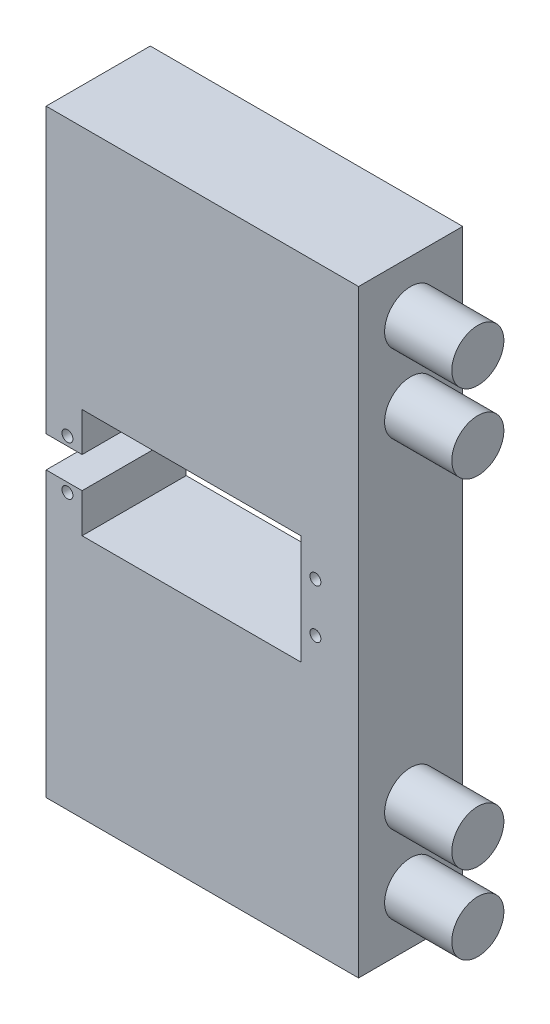
from build123d import *

# Parameters (mm, degrees)
SKETCH_5_W           = 60
SKETCH_5_H           = 115
EXTRUDE_2_DEPTH      = 20
SKETCH_1_R           = 1.05
CUT_EXTRUDE_4_DEPTH  = 20
SKETCH_6_R           = 5
EXTRUDE_3_DEPTH      = 13
SKETCH_22_W          = 21
SKETCH_22_H          = 21
CUT_EXTRUDE_9_DEPTH  = 17
SKETCH_22_6_W        = 21
SKETCH_22_6_H        = 21
CUT_EXTRUDE_10_DEPTH = 17


with BuildPart() as part:
    # Sketch 5 → Extrude 2 (new body)
    with BuildSketch(Plane.XY):
        with Locations((85.095319229, -3)):
            Rectangle(SKETCH_5_W, SKETCH_5_H)
    extrude(amount=EXTRUDE_2_DEPTH)

    # Sketch 1 → Cut-Extrude 4 (cut)
    with BuildSketch(Plane.XY):
        with Locations((59.19, 1.7)):
            Circle(SKETCH_1_R)
        with Locations((106.81, 1.7)):
            Circle(SKETCH_1_R)
        with Locations((106.81, -7.7)):
            Circle(SKETCH_1_R)
        with Locations((59.19, -7.7)):
            Circle(SKETCH_1_R)
        Polygon((55, -3), (55, 0), (62, 0), (62, 7.5), (104, 7.5), (104, -13.5), (62, -13.5), (62, -6), (55, -6), align=None)
    extrude(amount=CUT_EXTRUDE_4_DEPTH, mode=Mode.SUBTRACT)

    # Sketch 6 → Extrude 3 (add)
    with BuildSketch(Plane(origin=(115, 0, 0), x_dir=(0, 0, -1), z_dir=(1, 0, 0))):
        with Locations((-10, 44.5)):
            Circle(SKETCH_6_R)
        with Locations((-10, 29.5)):
            Circle(SKETCH_6_R)
        with Locations((-10, -35.5)):
            Circle(SKETCH_6_R)
        with Locations((-10, -50.5)):
            Circle(SKETCH_6_R)
    extrude(amount=EXTRUDE_3_DEPTH)

    # Sketch 22 → Cut-Extrude 9 (cut)
    with BuildSketch(Plane.XY):
        with Locations((85, 37.5)):
            Rectangle(SKETCH_22_W, SKETCH_22_H)
    extrude(amount=CUT_EXTRUDE_9_DEPTH, mode=Mode.SUBTRACT)

    # Sketch 22_6 → Cut-Extrude 10 (cut)
    with BuildSketch(Plane.XY):
        with Locations((85, -43.5)):
            Rectangle(SKETCH_22_6_W, SKETCH_22_6_H)
    extrude(amount=CUT_EXTRUDE_10_DEPTH, mode=Mode.SUBTRACT)


solid = part.part
